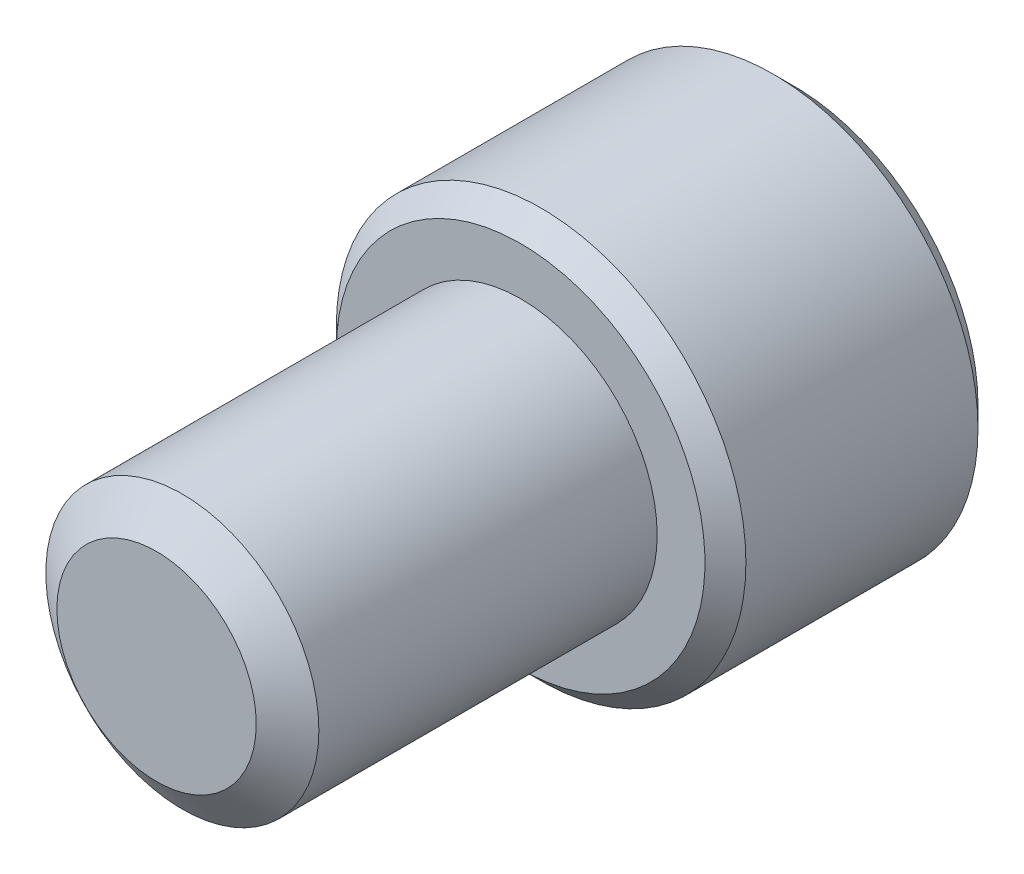
from build123d import *

# Parameters (mm, degrees)
SKETCH1_R          = 4.7625
EXTRUDE1_DEPTH     = 12.7
SKETCH6_R          = 7.14375
EXTRUDE2_DEPTH     = 9.525
CUT_EXTRUDE1_DEPTH = 5.953125
CHAMFER1_SIZE      = 0.714375


with BuildPart() as part:
    # Sketch1 → Extrude1 (new body)
    with BuildSketch(Plane.XY):
        Circle(SKETCH1_R)
    extrude(amount=-EXTRUDE1_DEPTH)

    # Sketch4 → Cut-Revolve1 (revolve, cut)
    with BuildSketch(Plane(origin=(0, 0, 0), x_dir=(0, 0, -1), z_dir=(1, 0, 0))):
        Polygon((0.899844757, 4.7625), (0, 3.477388504), (0, 4.7625), align=None)
    revolve(axis=Axis((0, 0, 0), (0, 0, -1)), mode=Mode.SUBTRACT)

    # Sketch6 → Extrude2 (add)
    with BuildSketch(Plane(origin=(0, 0, -12.7), x_dir=(-1, 0, 0), z_dir=(0, 0, -1))):
        Circle(SKETCH6_R)
    extrude(amount=EXTRUDE2_DEPTH)

    # Sketch7 → Cut-Extrude1 (cut)
    with BuildSketch(Plane(origin=(0, 0, -22.225), x_dir=(-1, 0, 0), z_dir=(0, 0, -1))):
        Polygon((0, 4.582717762), (-3.96875, 2.291358881), (-3.96875, -2.291358881), (0, -4.582717762), (3.96875, -2.291358881), (3.96875, 2.291358881), align=None)
    extrude(amount=-CUT_EXTRUDE1_DEPTH, mode=Mode.SUBTRACT)

    # Cut-Extrude2 cone 1 section (through the dimple's axis) → Cut-Extrude2 (revolve, cut)
    with BuildSketch(Plane(origin=(0, 0, -22.225), x_dir=(0, 1, 0), z_dir=(1, 0, 0))):
        Polygon((0, 0), (4.582717762, 0), (0, 4.582717762), align=None)
    revolve(axis=Axis((0, 0, -22.225), (0, 0, 1)), mode=Mode.SUBTRACT)

    # Chamfer1
    chamfer1_edges = [part.edges().sort_by_distance(p)[0] for p in [
        (7.14375, 0, -22.225),
        (7.14375, 0, -12.7),
    ]]
    chamfer(chamfer1_edges, length=CHAMFER1_SIZE)


solid = part.part
